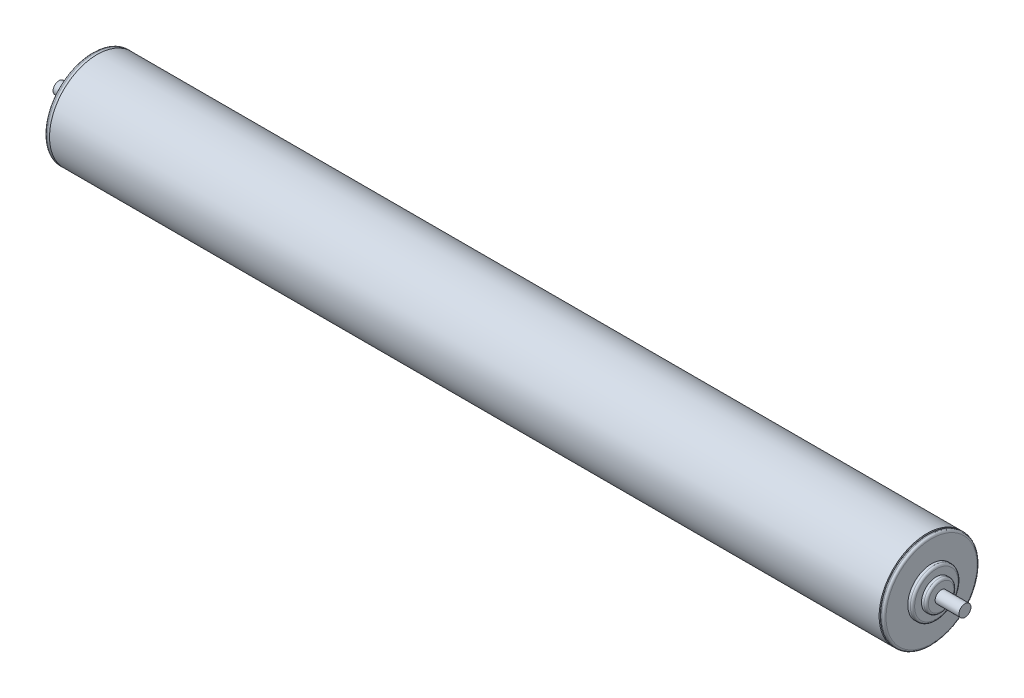
from build123d import *

# Parameters (mm, degrees)
REVOLVE1_ANGLE      = 360
FILLET1_R           = 1.143
SKETCH2_R           = 3.175
BOSS_EXTRUDE1_DEPTH = 12.7
BOSS_EXTRUDE2_START = -220.98
SKETCH3_R           = 25.4
BOSS_EXTRUDE2_DEPTH = 441.96


with BuildPart() as part:
    # Sketch1 → Revolve1 (revolve, symmetric)
    with BuildSketch(Plane.XY) as revolve1_sk:
        Polygon((-228.6, 0), (-228.6, 7.9375), (-226.06, 7.9375), (-226.06, 12.7), (-223.52, 12.7), (-223.52, 25.4), (-220.98, 25.4), (-220.98, 0), align=None)
    revolve(axis=Axis((-228.6, 0, 0), (1, 0, 0)), revolution_arc=REVOLVE1_ANGLE / 2)
    revolve(revolve1_sk.sketch, axis=Axis((-228.6, 0, 0), (-1, 0, 0)), revolution_arc=REVOLVE1_ANGLE / 2)

    # Fillet1
    fillet1_edges = [part.edges().sort_by_distance(p)[0] for p in [
        (-220.98, 0, 25.4),
        (-223.52, 0, 25.4),
        (-226.06, 0, 12.7),
        (-228.6, 0, 7.9375),
    ]]
    fillet(fillet1_edges, radius=FILLET1_R)

    # Sketch2 → Boss-Extrude1 (add)
    with BuildSketch(Plane.ZY.offset(228.6)):
        Circle(SKETCH2_R)
    extrude(amount=BOSS_EXTRUDE1_DEPTH)


with BuildPart() as body_2:
    # Mirror2: mirrored copy
    add(part.part.mirror(Plane(origin=(0, 0, 0), x_dir=(0, 0, 1), z_dir=(1, 0, 0))))


with BuildPart() as part_1:
    add(part.part)

    add(body_2.part)  # Boss-Extrude2 merges body 2
    # Sketch3 → Boss-Extrude2 (add)
    with BuildSketch(Plane(origin=(0, 0, 0), x_dir=(0, 0, -1), z_dir=(1, 0, 0)).offset(BOSS_EXTRUDE2_START)):
        Circle(SKETCH3_R)
    extrude(amount=BOSS_EXTRUDE2_DEPTH)


solid = part_1.part
